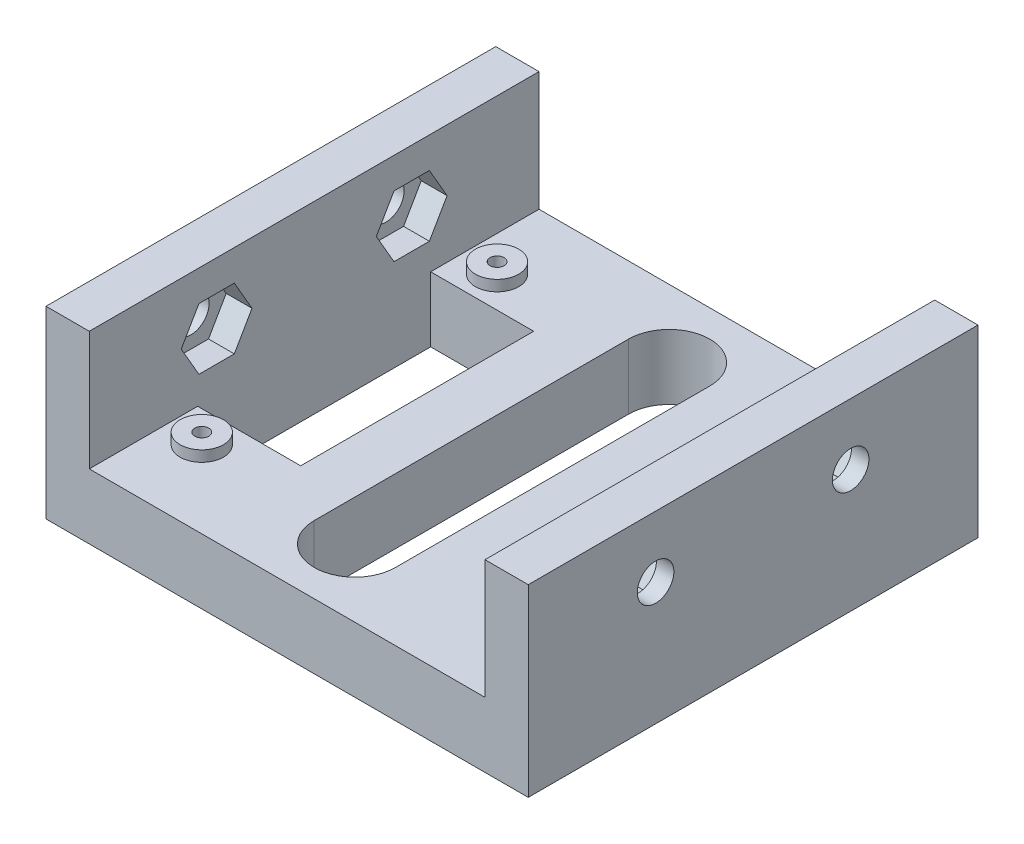
from build123d import *

# Parameters (mm, degrees)
SKETCH1_W                   = 89
SKETCH1_H                   = 83
SKETCH1_R                   = 1.3
MAIN_BODY_DEPTH             = 14
SKETCH2_W                   = 73.025
SKETCH2_H                   = 83
SKETCH2_R                   = 4
SCREW_RISER_DEPTH           = 2
SKETCH4_W                   = 7.9875
SKETCH4_H                   = 83
TOPPER_SUPPORT_DEPTH        = 20
MOUNT_START                 = -44.5
MOUNT_NUTS_DEPTH            = 41.275
F_9_32_MOUNT_HOLES_REACH    = 9.988
SKETCH5_R                   = 3.3734375
SKETCH8_W                   = 19.0125
SKETCH8_H                   = 43
MIDDLE_CUT_DEPTH            = 14
SKETCH9_R                   = 3.3734375
MOUNT_NUTS_P2_DEPTH         = 4.7625
SKETCH9_3_R                 = 3.3734375
F_9_32_MOUNT_HOLES_P2_DEPTH = 7.9875


with BuildPart() as part:
    # Sketch1 → Main Body (new body)
    with BuildSketch(Plane(origin=(0, 0, 0), x_dir=(1, 0, 0), z_dir=(0, 1, 0))):
        with Locations((0, 41.5)):
            Rectangle(SKETCH1_W, SKETCH1_H)
        with Locations((-30, 14.25)):
            Circle(SKETCH1_R, mode=Mode.SUBTRACT)
        with Locations((30, 14.25)):
            Circle(SKETCH1_R, mode=Mode.SUBTRACT)
        with BuildLine():
            Line((-7.5, 12.5), (-7.5, 70.5))
            ThreePointArc((-7.5, 70.5), (0, 78), (7.5, 70.5))
            Line((7.5, 70.5), (7.5, 12.5))
            ThreePointArc((7.5, 12.5), (0, 5), (-7.5, 12.5))
        make_face(mode=Mode.SUBTRACT)
        with Locations((-30, 68.75)):
            Circle(SKETCH1_R, mode=Mode.SUBTRACT)
        with Locations((30, 68.75)):
            Circle(SKETCH1_R, mode=Mode.SUBTRACT)
    extrude(amount=MAIN_BODY_DEPTH)

    # Sketch2 → Screw Riser (cut)
    with BuildSketch(Plane(origin=(0, 14, 0), x_dir=(1, 0, 0), z_dir=(0, 1, 0))):
        with Locations((0, 41.5)):
            Rectangle(SKETCH2_W, SKETCH2_H)
        with Locations((-30, 14.25)):
            Circle(SKETCH2_R, mode=Mode.SUBTRACT)
        with Locations((30, 14.25)):
            Circle(SKETCH2_R, mode=Mode.SUBTRACT)
        with Locations((-30, 68.75)):
            Circle(SKETCH2_R, mode=Mode.SUBTRACT)
        with Locations((30, 68.75)):
            Circle(SKETCH2_R, mode=Mode.SUBTRACT)
    extrude(amount=-SCREW_RISER_DEPTH, mode=Mode.SUBTRACT)

    # Sketch4 → Topper Support (add)
    with BuildSketch(Plane(origin=(0, 14, 0), x_dir=(1, 0, 0), z_dir=(0, 1, 0))):
        with Locations((-40.50625, 41.5)):
            Rectangle(SKETCH4_W, SKETCH4_H)
        with Locations((40.50625, 41.5)):
            Rectangle(SKETCH4_W, SKETCH4_H)
    extrude(amount=TOPPER_SUPPORT_DEPTH)

    # Sketch6 → Mount Nuts (cut)
    with BuildSketch(Plane.ZY.offset(44.5).offset(MOUNT_START)):
        Polygon((-52.96962719, 22.65546875), (-56.234813595, 28.3109375), (-62.765186405, 28.3109375), (-66.03037281, 22.65546875), (-62.765186405, 17), (-56.234813595, 17), align=None)
        Polygon((-16.96962719, 22.65546875), (-20.234813595, 28.3109375), (-26.765186405, 28.3109375), (-30.03037281, 22.65546875), (-26.765186405, 17), (-20.234813595, 17), align=None)
    extrude(amount=MOUNT_NUTS_DEPTH, mode=Mode.SUBTRACT)

    # Sketch5 → 9_32 Mount Holes (cut, up to next)
    with BuildSketch(Plane.ZY.offset(36.5125), mode=Mode.PRIVATE) as f_9_32_mount_holes_sk1:
        with Locations((-59.5, 22.65546875)):
            Circle(SKETCH5_R)
    f_9_32_mount_holes_tool1 = extrude(f_9_32_mount_holes_sk1.sketch, amount=F_9_32_MOUNT_HOLES_REACH, mode=Mode.PRIVATE) & part.part
    add(f_9_32_mount_holes_tool1.solids().sort_by_distance((-36.5125, 22.655469, -59.5))[0], mode=Mode.SUBTRACT)
    # Sketch5 → 9_32 Mount Holes (cut, up to next)
    with BuildSketch(Plane.ZY.offset(36.5125), mode=Mode.PRIVATE) as f_9_32_mount_holes_sk2:
        with Locations((-23.5, 22.65546875)):
            Circle(SKETCH5_R)
    f_9_32_mount_holes_tool2 = extrude(f_9_32_mount_holes_sk2.sketch, amount=F_9_32_MOUNT_HOLES_REACH, mode=Mode.PRIVATE) & part.part
    add(f_9_32_mount_holes_tool2.solids().sort_by_distance((-36.5125, 22.655469, -23.5))[0], mode=Mode.SUBTRACT)

    # Sketch8 → Middle Cut (cut)
    with BuildSketch(Plane(origin=(0, 14, 0), x_dir=(1, 0, 0), z_dir=(0, 1, 0))):
        with Locations((-27.00625, 41.5)):
            Rectangle(SKETCH8_W, SKETCH8_H)
        with Locations((27.00625, 41.5)):
            Rectangle(SKETCH8_W, SKETCH8_H)
    extrude(amount=-MIDDLE_CUT_DEPTH, mode=Mode.SUBTRACT)

    # Sketch9 → Mount Nuts p2 (cut)
    with BuildSketch(Plane.ZY.offset(-36.5125)):
        Polygon((-56.234813595, 17), (-62.765186405, 17), (-66.03037281, 22.65546875), (-62.765186405, 28.3109375), (-56.234813595, 28.3109375), (-52.96962719, 22.65546875), align=None)
        with Locations((-59.5, 22.65546875)):
            Circle(SKETCH9_R, mode=Mode.SUBTRACT)
        with Locations((-59.5, 22.65546875)):
            Circle(SKETCH9_R)
        Polygon((-20.234813595, 17), (-26.765186405, 17), (-30.03037281, 22.65546875), (-26.765186405, 28.3109375), (-20.234813595, 28.3109375), (-16.96962719, 22.65546875), align=None)
        with Locations((-23.5, 22.65546875)):
            Circle(SKETCH9_R, mode=Mode.SUBTRACT)
        with Locations((-23.5, 22.65546875)):
            Circle(SKETCH9_R)
    extrude(amount=-MOUNT_NUTS_P2_DEPTH, mode=Mode.SUBTRACT)

    # Sketch9_3 → 9_32 Mount Holes p2 (cut)
    with BuildSketch(Plane.ZY.offset(-36.5125)):
        with Locations((-59.5, 22.65546875)):
            Circle(SKETCH9_3_R)
        with Locations((-23.5, 22.65546875)):
            Circle(SKETCH9_3_R)
    extrude(amount=-F_9_32_MOUNT_HOLES_P2_DEPTH, mode=Mode.SUBTRACT)


solid = part.part
